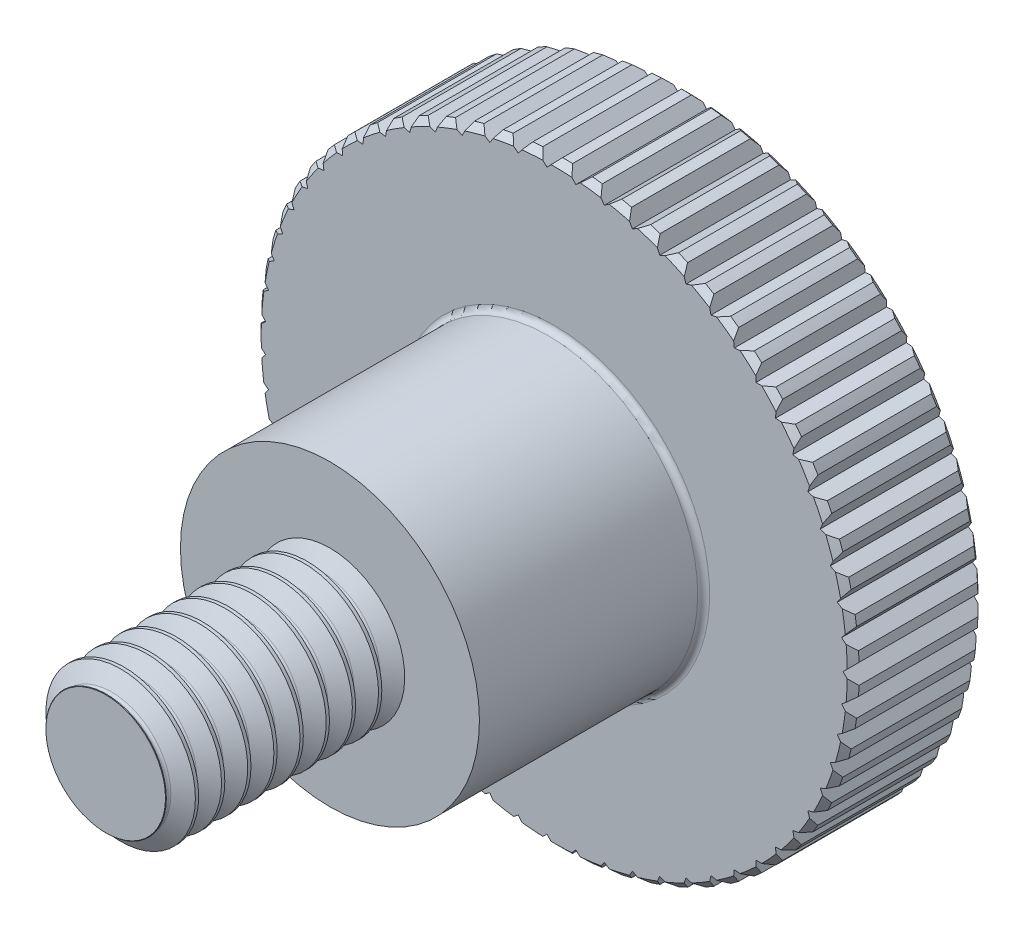
from build123d import *

# Parameters (mm, degrees)
SKETCH5_W           = 6
SKETCH5_H           = 2
THREAD_SIMPLE_COUNT = 9
THREAD_SIMPLE_PITCH = 0.7
SKETCH15_W          = 9.5
SKETCH15_H          = 8
CUT_GRIP_DEPTH      = 4.5
PATTERN_GRIP_COUNT  = 63


with BuildPart() as part:
    # Sketch5 → body (revolve)
    with BuildSketch(Plane(origin=(0, 0, 0), x_dir=(0, 0, -1), z_dir=(1, 0, 0))):
        with Locations((-3, 1)):
            Rectangle(SKETCH5_W, SKETCH5_H)
    revolve(axis=Axis((0, 0, 6), (0, 0, -1)))

    # Sketch11 → cut-chamfer-start (revolve, cut)
    with BuildSketch(Plane(origin=(0, 0, 0), x_dir=(0, 0, -1), z_dir=(1, 0, 0))):
        Polygon((-6, -2), (-6, -1.6), (-5.6, -2), align=None)
    revolve(axis=Axis((0, 0, 6), (0, 0, -1)), mode=Mode.SUBTRACT)

    # Sketch8 → thread-single (revolve, cut)
    with BuildSketch(Plane(origin=(0, 0, 0), x_dir=(0, 0, -1), z_dir=(1, 0, 0))):
        with BuildLine():
            Line((-0.6125, -2), (0, -2))
            Line((0, -2), (-0.240625, -1.583225274))
            ThreePointArc((-0.240625, -1.583225274), (-0.30625, -1.545336663), (-0.371875, -1.583225274))
            Line((-0.371875, -1.583225274), (-0.6125, -2))
        make_face()
    thread_single = revolve(axis=Axis((0, 0, 6), (0, 0, -1)), mode=Mode.SUBTRACT)

    # thread-simple: thread-single ×9
    with Locations(*[(0, 0, i * THREAD_SIMPLE_PITCH) for i in range(1, THREAD_SIMPLE_COUNT)]):
        add(thread_single, mode=Mode.SUBTRACT)

    # Sketch15 → body-head (revolve)
    with BuildSketch(Plane(origin=(0, 0, 0), x_dir=(0, 0, -1), z_dir=(1, 0, 0))):
        with Locations((4.75, -4)):
            Rectangle(SKETCH15_W, SKETCH15_H)
    revolve(axis=Axis((0, 0, -9.5), (0, 0, 1)))

    # Sketch19 → cut-head-profile (revolve, cut)
    with BuildSketch(Plane(origin=(0, 0, 0), x_dir=(0, 0, -1), z_dir=(1, 0, 0))):
        Polygon((9.34, -8), (9.5, -8), (9.5, -7.84), align=None)
        with BuildLine():
            Line((0, -8), (0, -4))
            Line((0, -4), (5.84, -4))
            ThreePointArc((5.84, -4), (5.953137085, -4.046862915), (6, -4.16))
            Line((6, -4.16), (6, -7.84))
            Line((6, -7.84), (6.16, -8))
            Line((6.16, -8), (0, -8))
        make_face()
    revolve(axis=Axis((0, 0, -9.5), (0, 0, 1)), mode=Mode.SUBTRACT)

    # Sketch23 → cut-grip (cut, through all)
    with BuildSketch(Plane.XY.offset(-6)):
        with BuildLine():
            Line((7.99555432, 0.266666667), (7.728887654, 0))
            Line((7.728887654, 0), (7.99555432, -0.266666667))
            ThreePointArc((7.99555432, -0.266666667), (8, 0), (7.99555432, 0.266666667))
        make_face()
    cut_grip = extrude(amount=-CUT_GRIP_DEPTH, mode=Mode.SUBTRACT)

    # pattern-grip: cut-grip ×63 about axis
    pattern_grip_axis = Axis((0, 0, 0), (0, 0, 1))
    for i in range(1, PATTERN_GRIP_COUNT):
        add(cut_grip.rotate(pattern_grip_axis, i * 360 / PATTERN_GRIP_COUNT), mode=Mode.SUBTRACT)


solid = part.part
